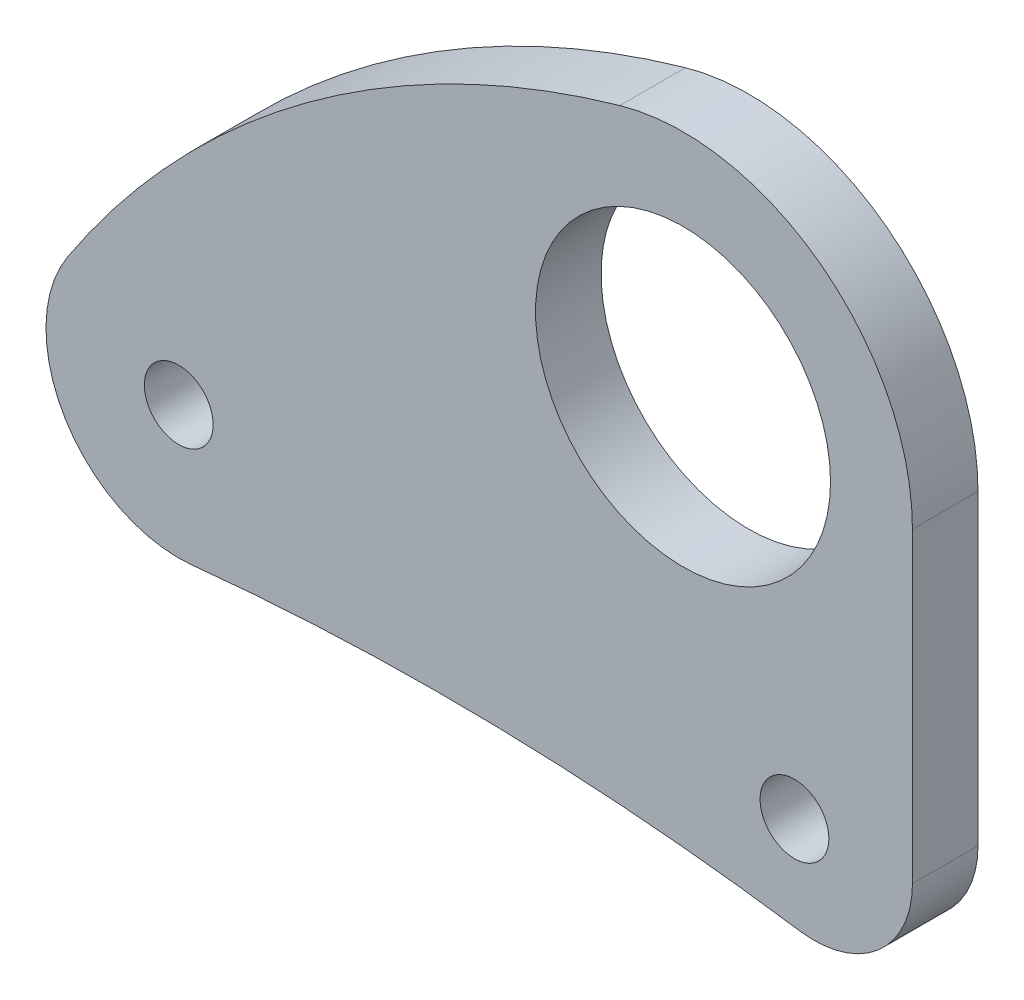
from build123d import *

# Parameters (mm, degrees)
ESQUISSE1_R        = 9
ESQUISSE1_R_2      = 2.1
BOSS_EXTRU_1_DEPTH = 4


with BuildPart() as part:
    # Esquisse1 → Boss.-Extru.1 (new body)
    with BuildSketch(Plane.XY):
        with BuildLine():
            Line((14, 0), (14, -18.735720858))
            ThreePointArc((14, -18.735720858), (11.923221563, -23.275360995), (7.13055581, -24.672392215))
            ThreePointArc((7.13055581, -24.672392215), (-11.382149549, -23.123814483), (-29.944297321, -23.875494465))
            ThreePointArc((-29.944297321, -23.875494465), (-37.690469305, -20.031379706), (-37.551840307, -11.384924901))
            ThreePointArc((-37.551840307, -11.384924901), (-22.940340069, 4.071410465), (-3.854513663, 13.458927313))
            ThreePointArc((-3.854513663, 13.458927313), (8.4272418, 11.179516789), (14, 0))
        make_face()
        Circle(ESQUISSE1_R, mode=Mode.SUBTRACT)
        with Locations((6.8, -18.914809013)):
            Circle(ESQUISSE1_R_2, mode=Mode.SUBTRACT)
        with Locations((-30.772589733, -15.817955655)):
            Circle(ESQUISSE1_R_2, mode=Mode.SUBTRACT)
    extrude(amount=BOSS_EXTRU_1_DEPTH)


solid = part.part
